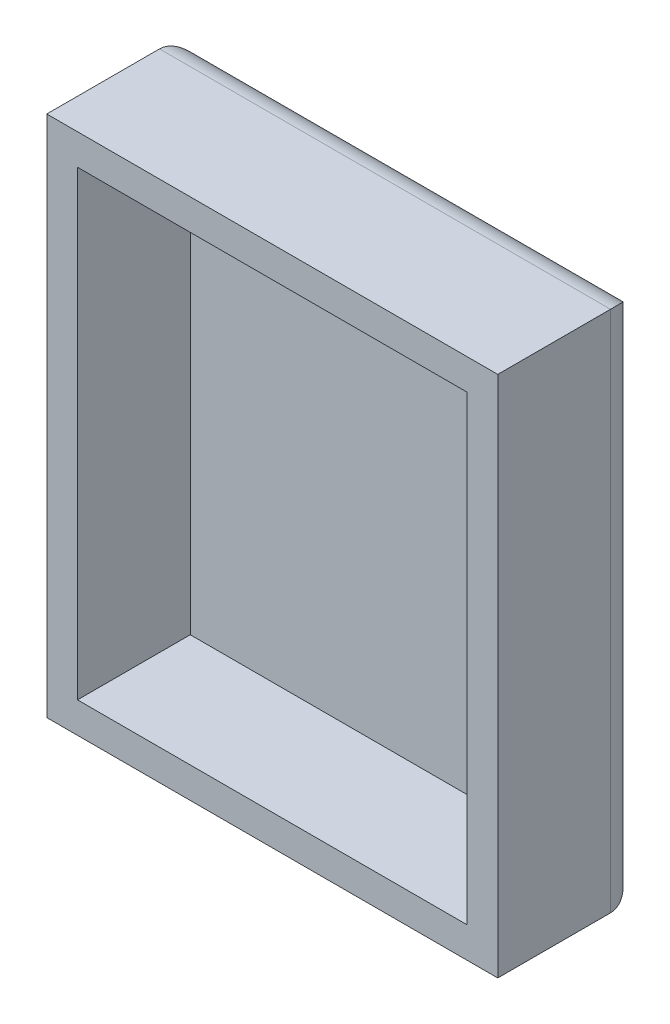
from build123d import *

# Parameters (mm, degrees)
SKETCH_1_W          = 44
SKETCH_1_H          = 51
EXTRUDE_2_DEPTH     = 14
SKETCH_2_W          = 38
SKETCH_2_H          = 45
CUT_EXTRUDE_1_DEPTH = 11
FILLET_1_R          = 3


with BuildPart() as part:
    # 草圖1 → 填料-伸長2 (new body)
    with BuildSketch(Plane.XY):
        with Locations((-37.776876722, -0.612244898)):
            Rectangle(SKETCH_1_W, SKETCH_1_H)
    extrude(amount=EXTRUDE_2_DEPTH)

    # 草圖2 → 除料-伸長1 (cut)
    with BuildSketch(Plane.XY.offset(14)):
        with Locations((-37.776876722, -0.612244898)):
            Rectangle(SKETCH_2_W, SKETCH_2_H)
    extrude(amount=-CUT_EXTRUDE_1_DEPTH, mode=Mode.SUBTRACT)

    # 圓角1
    fillet_1_edges = [part.edges().sort_by_distance(p)[0] for p in [
        (-37.776876722, 24.887755102, 0),
        (-15.776876722, -0.612244898, 0),
        (-37.776876722, -26.112244898, 0),
        (-59.776876722, -0.612244898, 0),
    ]]
    fillet(fillet_1_edges, radius=FILLET_1_R)


solid = part.part
